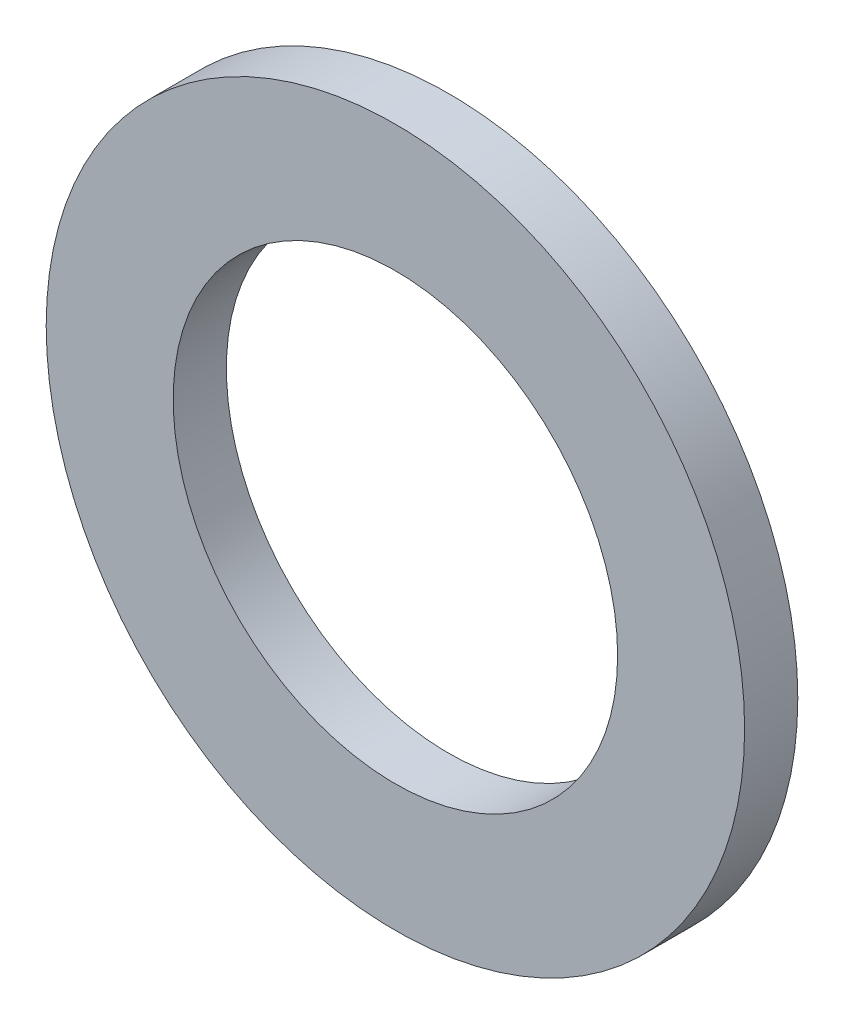
from build123d import *

# Parameters (mm, degrees)
SKETCH1_R           = 22
SKETCH1_R_2         = 14
EXTRUDE_THIN1_DEPTH = 3.35


with BuildPart() as part:
    # Sketch1 → Extrude-Thin1 (new body)
    with BuildSketch(Plane.XY):
        Circle(SKETCH1_R)
        Circle(SKETCH1_R_2, mode=Mode.SUBTRACT)
    extrude(amount=EXTRUDE_THIN1_DEPTH)


solid = part.part
